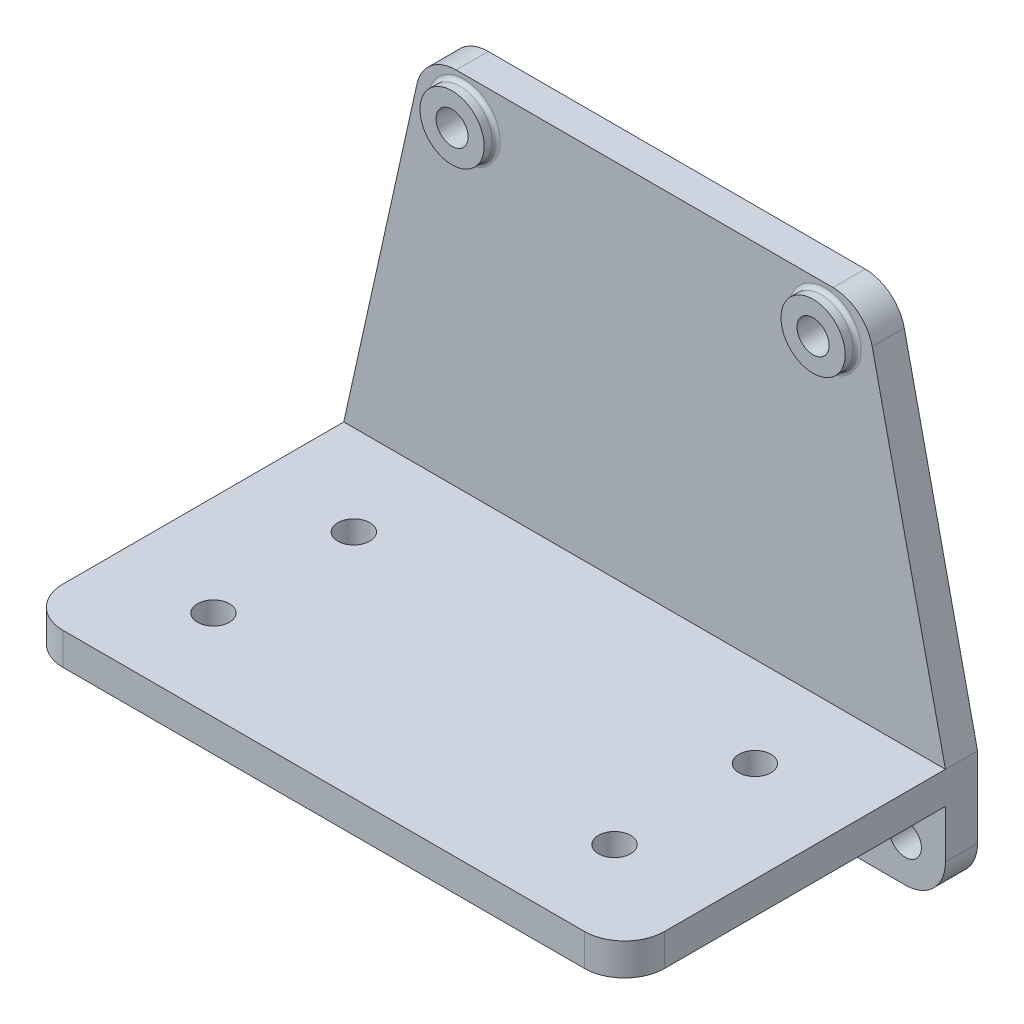
from build123d import *

# Parameters (mm, degrees)
EXTRUDE_1_DEPTH     = 8
SKETCH_2_R          = 4
CUT_EXTRUDE_1_DEPTH = 142.73566947
SKETCH_3_W          = 75
SKETCH_3_H          = 8
EXTRUDE_2_DEPTH     = 80
SKETCH_5_R          = 4
CUT_EXTRUDE_2_DEPTH = 147.523035732
RIB_1_REACH         = 156.091
SKETCH_6_WALL_W     = 393.151638598
SKETCH_6_WALL_H     = 8
FILLET_2_R          = 10
SKETCH_7_R          = 8
SKETCH_7_R_2        = 4
EXTRUDE_3_DEPTH     = 3
FILLET_3_R          = 1


with BuildPart() as part:
    # Эскиз1 → Бобышка-Вытянуть1 (new body)
    with BuildSketch(Plane.XY):
        Polygon((0, 0), (75, 0), (75, 30), (55, 120), (0, 120), align=None)
    extrude(amount=EXTRUDE_1_DEPTH)

    # Эскиз2 → Вырез-Вытянуть1 (cut, through all)
    with BuildSketch(Plane.XY.offset(8)):
        with Locations((45, 110)):
            Circle(SKETCH_2_R)
        with Locations((0, 10)):
            Circle(SKETCH_2_R)
        with Locations((65, 10)):
            Circle(SKETCH_2_R)
    extrude(amount=-CUT_EXTRUDE_1_DEPTH, mode=Mode.SUBTRACT)

    # Эскиз3 → Бобышка-Вытянуть2 (add)
    with BuildSketch(Plane.XY.offset(8)):
        with Locations((37.5, 26)):
            Rectangle(SKETCH_3_W, SKETCH_3_H)
    extrude(amount=EXTRUDE_2_DEPTH)

    # Эскиз5 → Вырез-Вытянуть2 (cut, through all)
    with BuildSketch(Plane(origin=(0, 30, 0), x_dir=(1, 0, 0), z_dir=(0, 1, 0))):
        with Locations(Location((50, -30.5, 0), (0, 0, 270))):
            Circle(SKETCH_5_R)
        with Locations(Location((50, -65.5, 0), (0, 0, 270))):
            Circle(SKETCH_5_R)
    extrude(amount=-CUT_EXTRUDE_2_DEPTH, mode=Mode.SUBTRACT)

    # Эскиз6 wall → Ребро1 (add, up to next)
    with BuildSketch(Plane(origin=(35, 11, 48), x_dir=(0, -0.265156483021, -0.964205392804), z_dir=(0, 0.964205392804, -0.265156483021)), mode=Mode.PRIVATE) as rib_1_sk1:
        Rectangle(SKETCH_6_WALL_W, SKETCH_6_WALL_H)
    rib_1_tool1 = extrude(rib_1_sk1.sketch, amount=RIB_1_REACH, mode=Mode.PRIVATE) - part.part
    add(rib_1_tool1.solids().sort_by_distance((35, 11, 48))[0])

    # Скругление2
    fillet_2_edges = [part.edges().sort_by_distance(p)[0] for p in [
        (55, 120, 4),
        (75, 0, 4),
        (75, 26, 88),
    ]]
    fillet(fillet_2_edges, radius=FILLET_2_R)

    # Зеркальное отражение1: part across plane


with BuildPart() as part_1:
    add(part.part)
    add(part.part.mirror(Plane(origin=(0, 120, 8), x_dir=(0, 0, 1), z_dir=(1, 0, 0))))

    # Эскиз7 → Бобышка-Вытянуть3 (add)
    with BuildSketch(Plane.XY.offset(8)):
        with Locations((-45, 110)):
            Circle(SKETCH_7_R)
        with Locations(Location((-45, 110, 0), (0, 0, 180))):
            Circle(SKETCH_7_R_2, mode=Mode.SUBTRACT)
        with Locations((45, 110)):
            Circle(SKETCH_7_R)
        with Locations((45, 110)):
            Circle(SKETCH_7_R_2, mode=Mode.SUBTRACT)
    extrude(amount=EXTRUDE_3_DEPTH)

    # Скругление3
    fillet_3_edges = [part_1.edges().sort_by_distance(p)[0] for p in [
        (-53, 110, 8),
        (37, 110, 8),
    ]]
    fillet(fillet_3_edges, radius=FILLET_3_R)


solid = part_1.part
